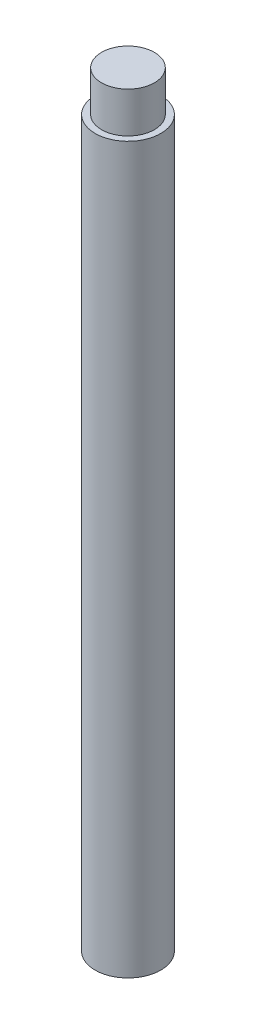
from build123d import *

# Parameters (mm, degrees)
SKETCH1_R           = 4.85
SKETCH1_R_2         = 4
BOSS_EXTRUDE1_DEPTH = 52.5
SKETCH2_R           = 3.9
BOSS_EXTRUDE2_DEPTH = 8
SKETCH3_R           = 4.85
BOSS_EXTRUDE3_DEPTH = 2
CHAMFER1_SIZE       = 4
SKETCH4_R           = 4.85
BOSS_EXTRUDE4_DEPTH = 107
SKETCH5_R           = 4
CUT_EXTRUDE1_DEPTH  = 14
CHAMFER2_SIZE       = 3.9


with BuildPart() as part:
    # Sketch1 → Boss-Extrude1 (new body, symmetric)
    with BuildSketch(Plane(origin=(0, 0, 0), x_dir=(1, 0, 0), z_dir=(0, 1, 0))):
        Circle(SKETCH1_R)
        Circle(SKETCH1_R_2, mode=Mode.SUBTRACT)
    extrude(amount=BOSS_EXTRUDE1_DEPTH, both=True)



with BuildPart() as body_2:
    # Sketch2 → Boss-Extrude2 (new body)
    with BuildSketch(Plane(origin=(0, 52.5, 0), x_dir=(1, 0, 0), z_dir=(0, 1, 0))):
        Circle(SKETCH2_R)
    extrude(amount=BOSS_EXTRUDE2_DEPTH)


with BuildPart() as part_1:
    add(part.part)

    add(body_2.part)  # Boss-Extrude3 merges body 2
    # Sketch3 → Boss-Extrude3 (add)
    with BuildSketch(Plane(origin=(0, 52.5, 0), x_dir=(1, 0, 0), z_dir=(0, 1, 0))):
        Circle(SKETCH3_R)
    extrude(amount=BOSS_EXTRUDE3_DEPTH)

    # Chamfer1
    chamfer1_edges = [part_1.edges().sort_by_distance(p)[0] for p in [
        (-4, 52.5, 0),
    ]]
    chamfer(chamfer1_edges, length=CHAMFER1_SIZE)

    # Sketch4 → Boss-Extrude4 (add)
    with BuildSketch(Plane.XZ.offset(52.5)):
        Circle(SKETCH4_R)
    extrude(amount=-BOSS_EXTRUDE4_DEPTH)

    # Sketch5 → Cut-Extrude1 (cut)
    with BuildSketch(Plane.XZ.offset(52.5)):
        Circle(SKETCH5_R)
    extrude(amount=-CUT_EXTRUDE1_DEPTH, mode=Mode.SUBTRACT)

    # Chamfer2
    chamfer2_edges = [part_1.edges().sort_by_distance(p)[0] for p in [
        (-4, -38.5, 0),
    ]]
    chamfer(chamfer2_edges, length=CHAMFER2_SIZE)


solid = part_1.part
